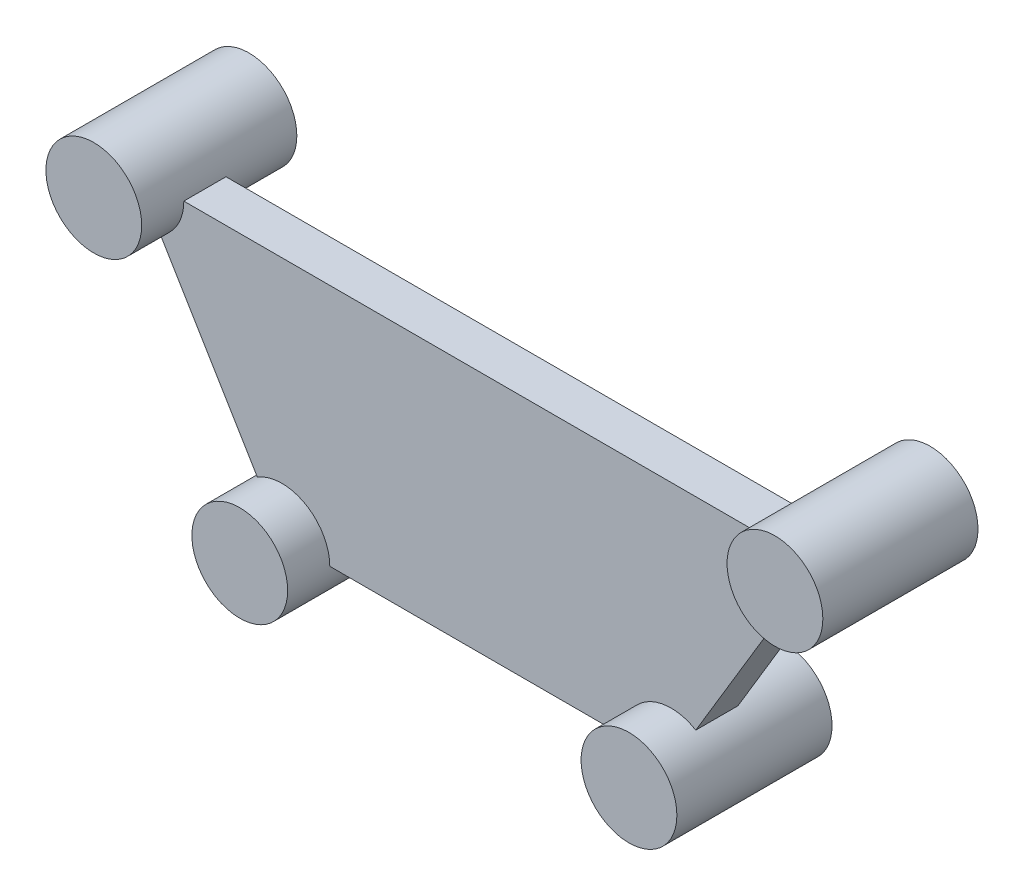
from build123d import *

# Parameters (mm, degrees)
BOSS_EXTRUDE1_DEPTH      = 22
BOSS_EXTRUDE2_DEPTH      = 44
BOSS_EXTRUDE2_DEPTH_BACK = 37
SKETCH1_3_R              = 25


with BuildPart() as part:
    # Sketch1 → Boss-Extrude1 (new body)
    with BuildSketch(Plane.XY):
        Polygon((-177.8, 78.062396106), (177.8, 78.062396106), (101.6, -48.937603894), (-101.6, -48.937603894), align=None)
    extrude(amount=BOSS_EXTRUDE1_DEPTH)

    # Sketch1_3 → Boss-Extrude2 (add, two sides: drawn at the far end of the back side and taken through both)
    with BuildSketch(Plane.XY.offset(-BOSS_EXTRUDE2_DEPTH_BACK)):
        with Locations((177.8, 78.062396106)):
            Circle(SKETCH1_3_R)
        with Locations((101.6, -48.937603894)):
            Circle(SKETCH1_3_R)
        with Locations((-101.6, -48.937603894)):
            Circle(SKETCH1_3_R)
        with Locations((-177.8, 78.062396106)):
            Circle(SKETCH1_3_R)
    extrude(amount=BOSS_EXTRUDE2_DEPTH + BOSS_EXTRUDE2_DEPTH_BACK)


solid = part.part
